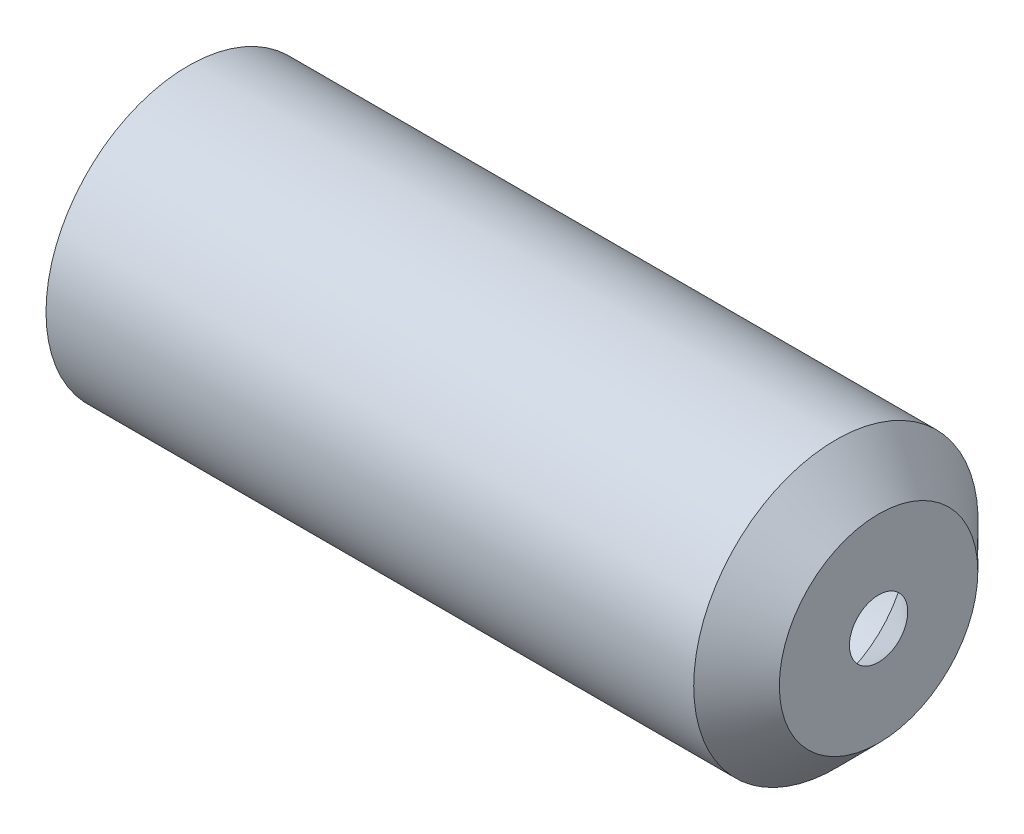
from build123d import *


with BuildPart() as part:
    # Schizzo1 → Rivoluzione1 (revolve)
    with BuildSketch(Plane.XY):
        Polygon((-139.6602, 18.8), (-12.6602, 18.8), (0.1398, 5.9), (0.1398, 20.097485817), (-8.495252833, 28.8), (-139.6602, 28.8), align=None)
    revolve(axis=Axis((-0.252144605, 0, 0), (1, 0, 0)))


solid = part.part
